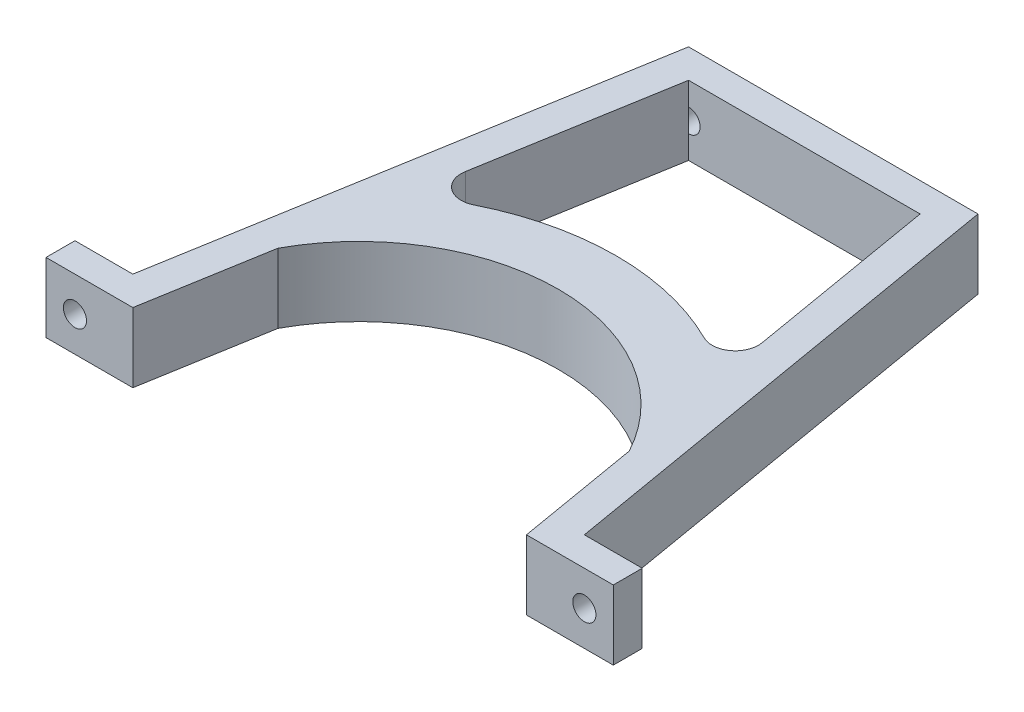
from build123d import *

# Parameters (mm, degrees)
BOSS_EXTRUDE1_DEPTH = 12
SKETCH2_R           = 2
CUT_EXTRUDE4_DEPTH  = 12
CUT_EXTRUDE5_START  = -77
SKETCH2_3_R         = 2
CUT_EXTRUDE5_DEPTH  = 12


with BuildPart() as part:
    # Sketch1 → Boss-Extrude1 (new body)
    with BuildSketch(Plane(origin=(0, 0, 0), x_dir=(1, 0, 0), z_dir=(0, 1, 0))):
        with BuildLine():
            Line((49, -5), (49, 0))
            Line((49, 0), (39, 0))
            Line((39, 0), (25, 82))
            Line((25, 82), (-25, 82))
            Line((-25, 82), (-39, 0))
            Line((-39, 0), (-49, 0))
            Line((-49, 0), (-49, -5))
            Line((-49, -5), (-34, -5))
            Line((-34, -5), (-30.343379621, 16.417347933))
            ThreePointArc((-30.343379621, 16.417347933), (0, 34.5), (30.343379621, 16.417347933))
            Line((30.343379621, 16.417347933), (34, -5))
            Line((34, -5), (49, -5))
        make_face()
        with BuildLine():
            Line((20, 77), (25.624396188, 44.057108045))
            ThreePointArc((25.624396188, 44.057108045), (24.064523617, 40.171296717), (19.893289621, 39.805866754))
            ThreePointArc((19.893289621, 39.805866754), (0, 44.5), (-19.893289621, 39.805866754))
            ThreePointArc((-19.893289621, 39.805866754), (-24.064523617, 40.171296717), (-25.624396188, 44.057108045))
            Line((-25.624396188, 44.057108045), (-20, 77))
            Line((-20, 77), (20, 77))
        make_face(mode=Mode.SUBTRACT)
    extrude(amount=BOSS_EXTRUDE1_DEPTH)

    # Sketch2 → Cut-Extrude4 (cut)
    with BuildSketch(Plane.XY):
        with Locations((-44, 6)):
            Circle(SKETCH2_R)
        with Locations((44, 6)):
            Circle(SKETCH2_R)
    extrude(amount=CUT_EXTRUDE4_DEPTH, mode=Mode.SUBTRACT)

    # Sketch2_3 → Cut-Extrude5 (cut)
    with BuildSketch(Plane.XY.offset(CUT_EXTRUDE5_START)):
        with Locations((-20, 6)):
            Circle(SKETCH2_3_R)
        with Locations((20, 6)):
            Circle(SKETCH2_3_R)
    extrude(amount=-CUT_EXTRUDE5_DEPTH, mode=Mode.SUBTRACT)


solid = part.part
